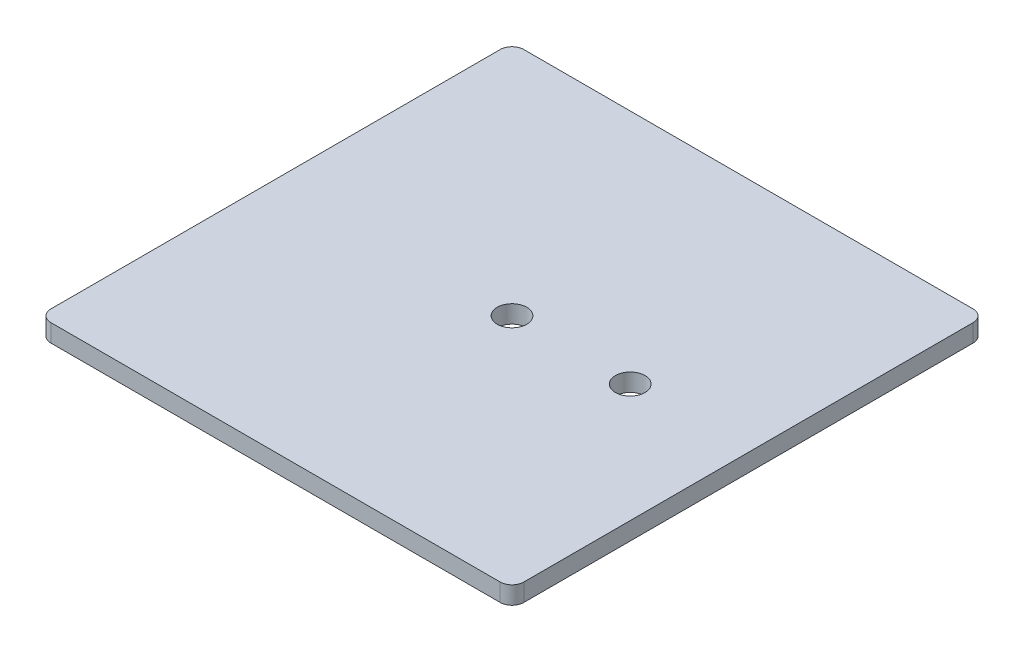
from build123d import *

# Parameters (mm, degrees)
ESQUISSE1_W      = 80
ESQUISSE1_H      = 80
ESQUISSE1_R      = 2.5
EXTRUSION1_DEPTH = 3
CONG_1_R         = 2


with BuildPart() as part:
    # Esquisse1 → Extrusion1 (new body)
    with BuildSketch(Plane(origin=(0, 0, 0), x_dir=(1, 0, 0), z_dir=(0, 1, 0))):
        with Locations((40, 40)):
            Rectangle(ESQUISSE1_W, ESQUISSE1_H)
        with Locations((40, 40)):
            Circle(ESQUISSE1_R, mode=Mode.SUBTRACT)
        with Locations((60, 40)):
            Circle(ESQUISSE1_R, mode=Mode.SUBTRACT)
    extrude(amount=EXTRUSION1_DEPTH)

    # Congé1
    cong_1_edges = [part.edges().sort_by_distance(p)[0] for p in [
        (0, 1.5, -80),
        (80, 1.5, -80),
        (80, 1.5, 0),
        (0, 1.5, 0),
    ]]
    fillet(cong_1_edges, radius=CONG_1_R)


solid = part.part
